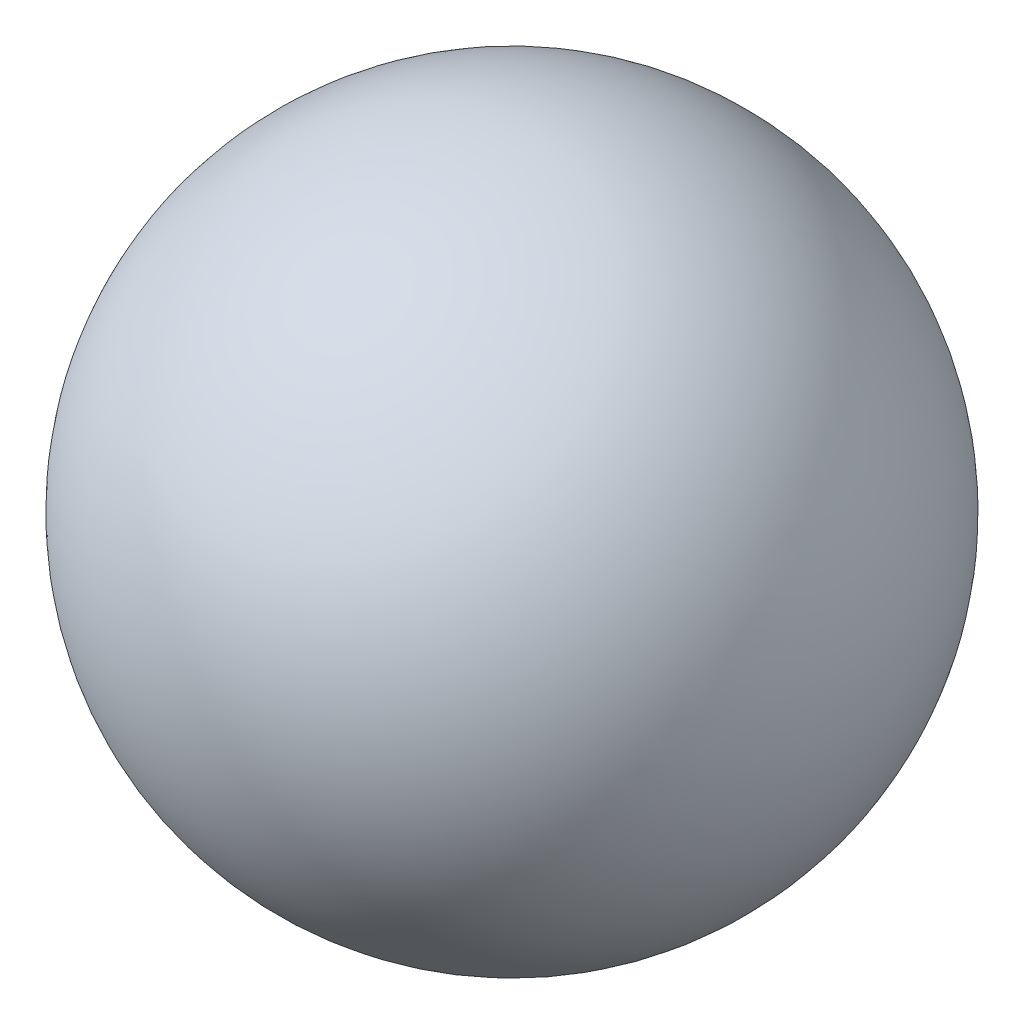
from build123d import *


with BuildPart() as part:
    # 草图1 → 旋转10 (revolve)
    with BuildSketch(Plane.XY):
        with BuildLine():
            Line((-6, 0), (6, 0))
            ThreePointArc((6, 0), (0, 6), (-6, 0))
        make_face()
    revolve(axis=Axis((0, 0, 0), (1, 0, 0)))


solid = part.part
